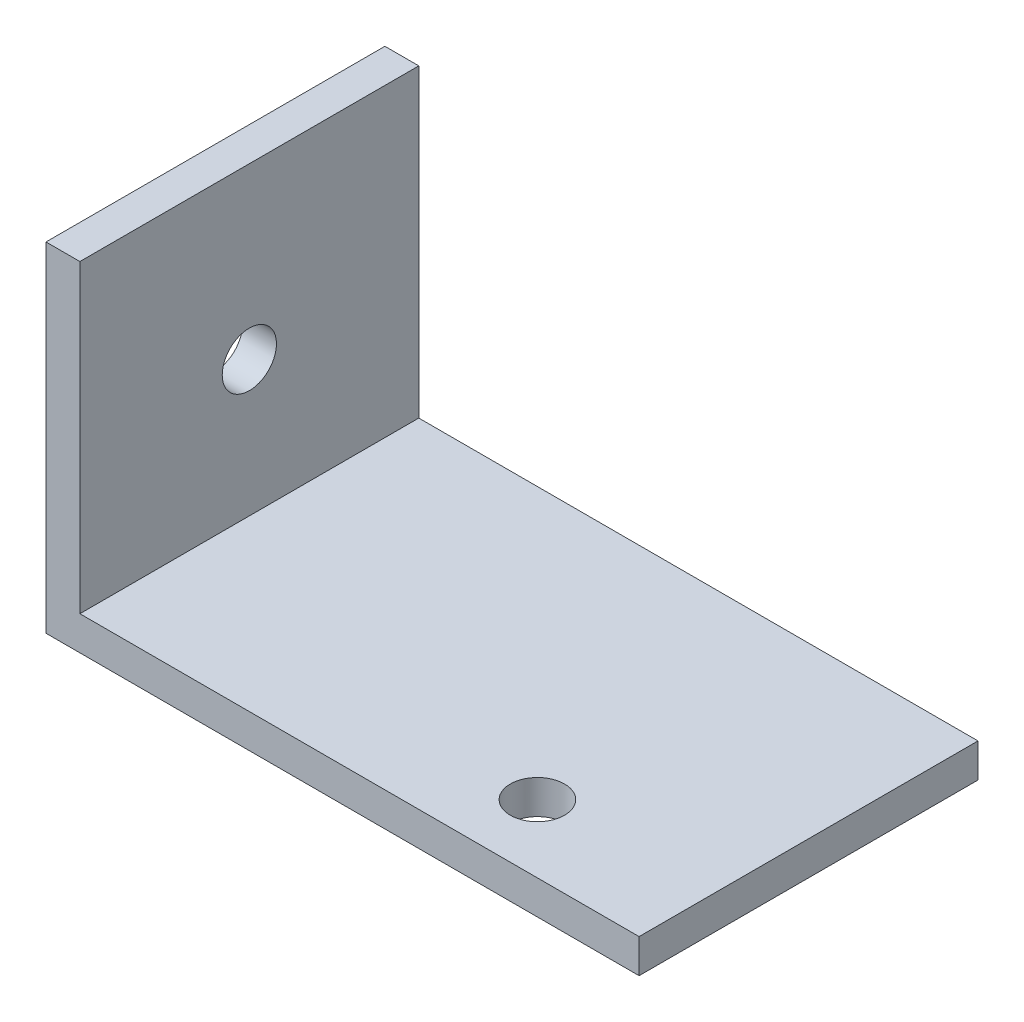
from build123d import *

# Parameters (mm, degrees)
EXTRUDE_1_DEPTH     = 20
SKETCH_3_R          = 1.6
CUT_EXTRUDE_2_DEPTH = 36
SKETCH_4_R          = 1.6
CUT_EXTRUDE_3_DEPTH = 21


with BuildPart() as part:
    # Эскиз1 → Бобышка-Вытянуть1 (new body)
    with BuildSketch(Plane.XY):
        Polygon((0, 0), (35, 0), (35, 2), (2, 2), (2, 20), (0, 20), align=None)
    extrude(amount=EXTRUDE_1_DEPTH)

    # Эскиз3 → Вырез-Вытянуть2 (cut, through all)
    with BuildSketch(Plane.ZY):
        with Locations((10, 10)):
            Circle(SKETCH_3_R)
    extrude(amount=-CUT_EXTRUDE_2_DEPTH, mode=Mode.SUBTRACT)

    # Эскиз4 → Вырез-Вытянуть3 (cut, through all)
    with BuildSketch(Plane.XZ):
        with Locations((25, 16)):
            Circle(SKETCH_4_R)
    extrude(amount=-CUT_EXTRUDE_3_DEPTH, mode=Mode.SUBTRACT)


solid = part.part
